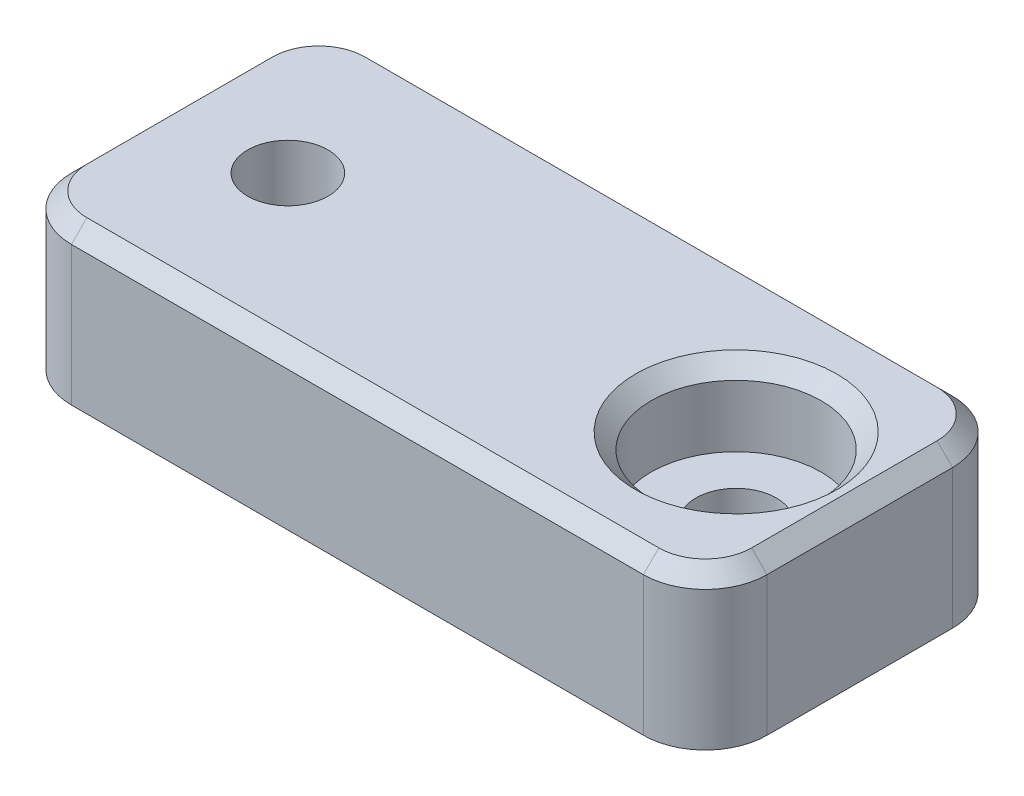
from build123d import *

# Parameters (mm, degrees)
BOSS_EXTRUDE1_DEPTH = 22.5
SKETCH2_R           = 2.6
CUT_EXTRUDE1_DEPTH  = 11.5
SKETCH3_W           = 14
SKETCH3_H           = 20
CUT_EXTRUDE2_DEPTH  = 1.5
DRAFT1_ANGLE        = 45
FILLET1_R           = 4
SKETCH6_R           = 5.5
CUT_EXTRUDE3_DEPTH  = 5
CHAMFER2_SIZE       = 1


with BuildPart() as part:
    # Sketch1 → Boss-Extrude1 (new body, symmetric)
    with BuildSketch(Plane(origin=(0, 0, 0), x_dir=(0, 0, -1), z_dir=(1, 0, 0))):
        Polygon((-10, 5), (10, 5), (10, -5), (2.95, -5), (2.818767005, -6.5), (-2.818767005, -6.5), (-2.95, -5), (-10, -5), align=None)
    extrude(amount=BOSS_EXTRUDE1_DEPTH, both=True)

    # Sketch2 → Cut-Extrude1 (cut)
    with BuildSketch(Plane(origin=(0, 5, 0), x_dir=(1, 0, 0), z_dir=(0, 1, 0))):
        with Locations((-14.5, 0)):
            Circle(SKETCH2_R)
        with Locations((14.5, 0)):
            Circle(SKETCH2_R)
    extrude(amount=-CUT_EXTRUDE1_DEPTH, mode=Mode.SUBTRACT)

    # Sketch3 → Cut-Extrude2 (cut)
    with BuildSketch(Plane.XZ.offset(5)):
        with Locations((15.5, 0)):
            Rectangle(SKETCH3_W, SKETCH3_H)
        with Locations((-15.5, 0)):
            Rectangle(SKETCH3_W, SKETCH3_H)
    extrude(amount=CUT_EXTRUDE2_DEPTH, mode=Mode.SUBTRACT)

    # Draft1
    draft1_faces = [part.faces().sort_by_distance(p)[0] for p in [
        (8.5, -5.74431278, 0),
        (-8.5, -5.74431278, 0),
    ]]
    draft(draft1_faces, Plane(origin=(22.5, -6.5, -2.818767005), x_dir=(0, 0, -1), z_dir=(0, -1, 0)), DRAFT1_ANGLE)

    # Fillet1
    fillet1_edges = [part.edges().sort_by_distance(p)[0] for p in [
        (-22.5, 0, -10),
        (22.5, 0, 10),
        (22.5, 0, -10),
        (-22.5, 0, 10),
    ]]
    fillet(fillet1_edges, radius=FILLET1_R)

    # Sketch6 → Cut-Extrude3 (cut)
    with BuildSketch(Plane(origin=(0, 5, 0), x_dir=(1, 0, 0), z_dir=(0, 1, 0))):
        with Locations((14.5, 0)):
            Circle(SKETCH6_R)
    extrude(amount=-CUT_EXTRUDE3_DEPTH, mode=Mode.SUBTRACT)

    # Chamfer2
    chamfer2_edges = [part.edges().sort_by_distance(p)[0] for p in [
        (9, 5, 0),
        (22.5, 5, 0),
        (-22.5, 5, 0),
        (0, 5, 10),
        (0, 5, -10),
        (-21.328427125, 5, 8.828427125),
        (-21.328427125, 5, -8.828427125),
        (21.328427125, 5, 8.828427125),
        (21.328427125, 5, -8.828427125),
    ]]
    chamfer(chamfer2_edges, length=CHAMFER2_SIZE)


solid = part.part
